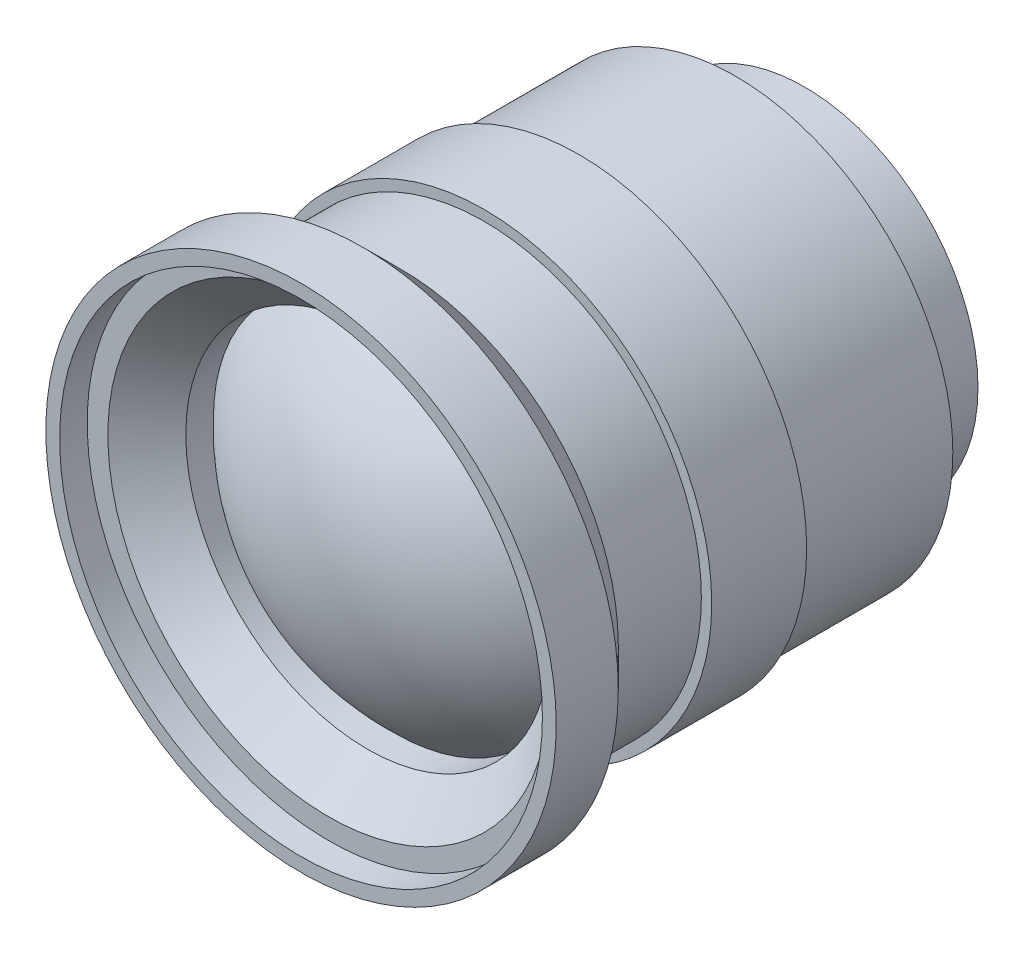
from build123d import *


with BuildPart() as part:
    # Sketch1 → Revolve1 (revolve)
    with BuildSketch(Plane(origin=(0, 0, 0), x_dir=(0, 0, -1), z_dir=(1, 0, 0))):
        with BuildLine():
            Line((0, 0), (0, 12.575))
            Line((0, 12.575), (-5, 12.575))
            Line((-5, 12.575), (-5, 15.75))
            Line((-5, 15.75), (-16.345423433, 15.75))
            Line((-16.345423433, 15.75), (-16.345423433, 16.5))
            Line((-16.345423433, 16.5), (-23.228752503, 16.5))
            Line((-23.228752503, 16.5), (-23.228752503, 15.75))
            Line((-23.228752503, 15.75), (-29.251665438, 15.75))
            Line((-29.251665438, 15.75), (-32.001665438, 18.5))
            Line((-32.001665438, 18.5), (-36.5, 18.5))
            Line((-36.5, 18.5), (-36.5, 17.5))
            Line((-36.5, 17.5), (-34.5, 17.5))
            Line((-34.5, 17.5), (-34.5, 16))
            Line((-34.5, 16), (-31.676037941, 13.176037941))
            Line((-31.676037941, 13.176037941), (-29.676037941, 13.176037941))
            ThreePointArc((-29.676037941, 13.176037941), (-33.951349088, 7.19510787), (-35.461393008, 0))
            Line((-35.461393008, 0), (0, 0))
        make_face()
    revolve(axis=Axis((0, 0, 35.461393008), (0, 0, -1)))


solid = part.part
